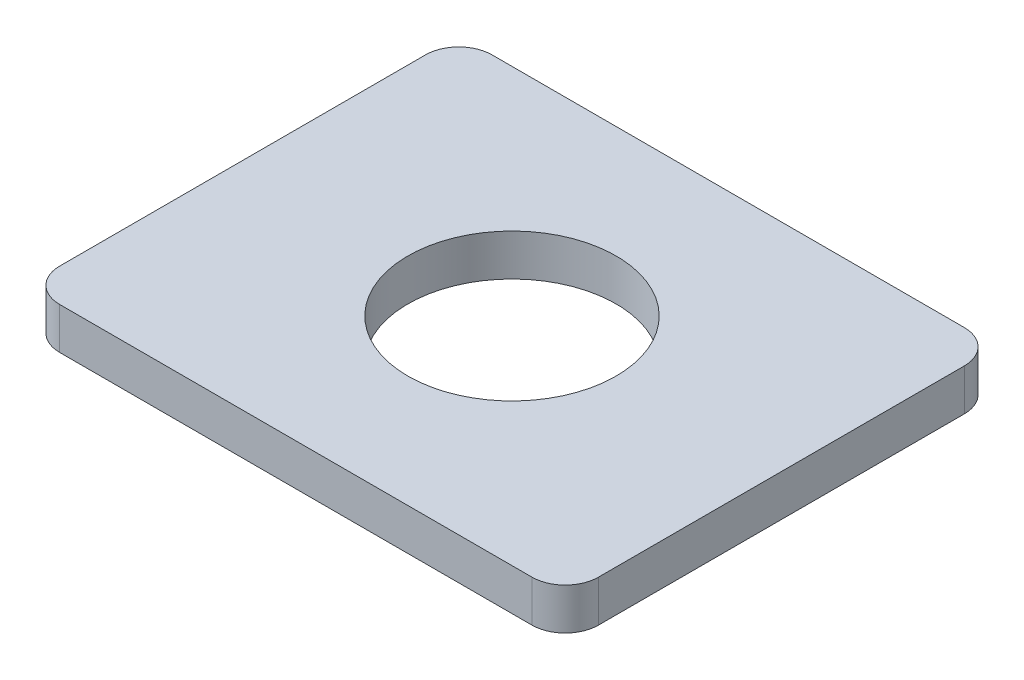
from build123d import *

# Parameters (mm, degrees)
BOSS_EXTRUDE1_DEPTH = 3.175
SKETCH2_R           = 7.9502
CUT_EXTRUDE1_DEPTH  = 4.175


with BuildPart() as part:
    # Sketch1 → Boss-Extrude1 (new body)
    with BuildSketch(Plane(origin=(0, 0, 0), x_dir=(1, 0, 0), z_dir=(0, 1, 0))):
        with BuildLine():
            Line((18.034, -16.51), (-18.034, -16.51))
            ThreePointArc((-18.034, -16.51), (-19.830051224, -15.766051224), (-20.574, -13.97))
            Line((-20.574, -13.97), (-20.574, 13.97))
            ThreePointArc((-20.574, 13.97), (-19.830051224, 15.766051224), (-18.034, 16.51))
            Line((-18.034, 16.51), (18.034, 16.51))
            ThreePointArc((18.034, 16.51), (19.830051224, 15.766051224), (20.574, 13.97))
            Line((20.574, 13.97), (20.574, -13.97))
            ThreePointArc((20.574, -13.97), (19.830051224, -15.766051224), (18.034, -16.51))
        make_face()
    extrude(amount=BOSS_EXTRUDE1_DEPTH)

    # Sketch2 → Cut-Extrude1 (cut, through all)
    with BuildSketch(Plane(origin=(0, 3.175, 0), x_dir=(1, 0, 0), z_dir=(0, 1, 0))):
        Circle(SKETCH2_R)
    extrude(amount=-CUT_EXTRUDE1_DEPTH, mode=Mode.SUBTRACT)


solid = part.part
